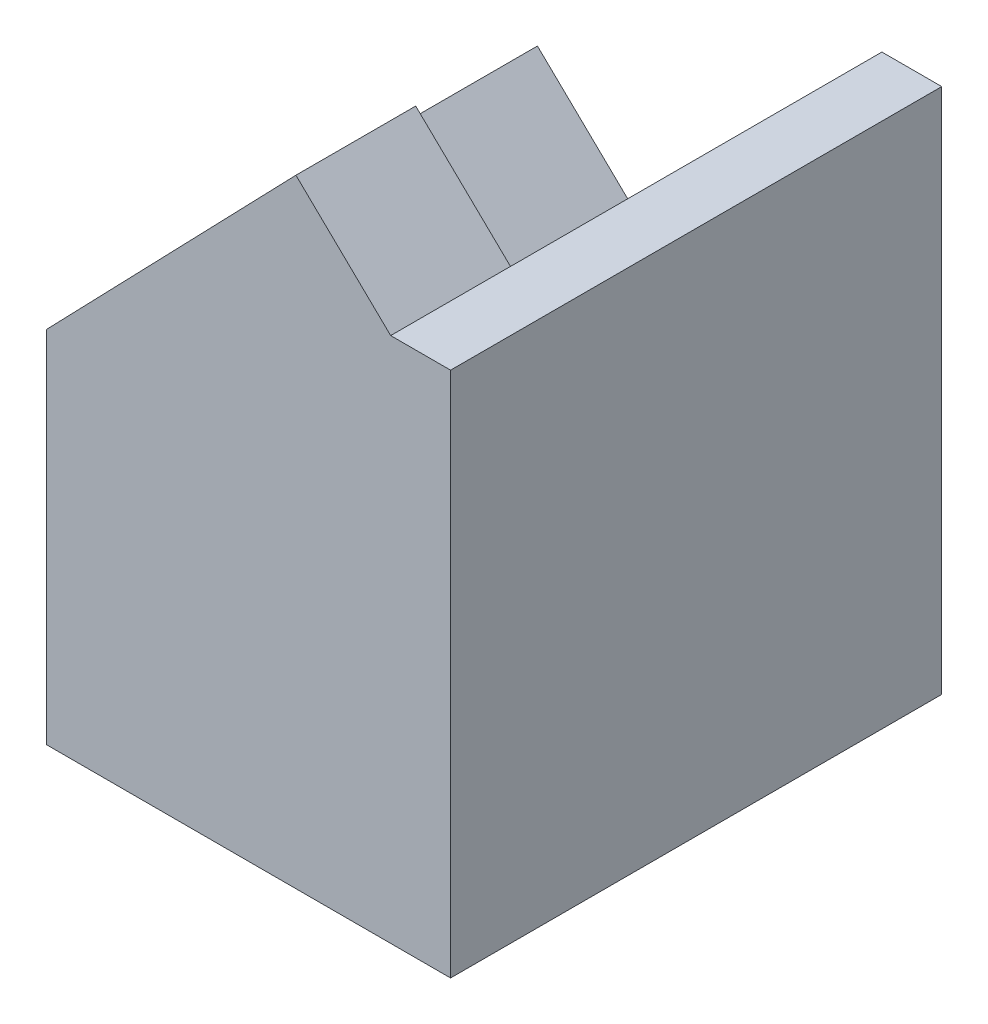
from build123d import *

# Parameters (mm, degrees)
BOSS_EXTRUDE1_DEPTH       = 8.2
CUT_EXTRUDE1_DEPTH        = 2.2
SKETCH3_W                 = 6.75
SKETCH3_H                 = 8.2
BOSS_EXTRUDE2_DEPTH       = 4
M2X0_4_TAPPED_HOLE1_D     = 1.6
M2X0_4_TAPPED_HOLE1_DEPTH = 4.7
M2X0_4_TAPPED_HOLE1_TIP   = 0.480688495
F_1_5MM_DOWEL_HOLE1_D     = 1.5
F_1_5MM_DOWEL_HOLE1_DEPTH = 3
F_1_5MM_DOWEL_HOLE1_TIP   = 0.450645464


with BuildPart() as part:
    # Sketch1 → Boss-Extrude1 (new body)
    with BuildSketch(Plane.XY):
        Polygon((0, 0), (6.75, 0), (6.75, 4.788271091), (5.75, 4.788271091), (4.167950223, 6.316038802), (0, 2), align=None)
    extrude(amount=BOSS_EXTRUDE1_DEPTH)

    # Sketch2 → Cut-Extrude1 (cut)
    with BuildSketch(Plane(origin=(-0.999390827, 0.965100503, 0), x_dir=(0.69465837, 0.7193398, 0), z_dir=(-0.7193398, 0.69465837, 0))):
        with BuildLine():
            Line((8.438679601, 0), (8.438679601, -6.2))
            Line((8.438679601, -6.2), (3.438679601, -6.2))
            Line((3.438679601, -6.2), (3.438679601, -6.45))
            ThreePointArc((3.438679601, -6.45), (2.438679601, -7.45), (1.438679601, -6.45))
            Line((1.438679601, -6.45), (1.438679601, 0))
            Line((1.438679601, 0), (8.438679601, 0))
        make_face()
    extrude(amount=-CUT_EXTRUDE1_DEPTH, mode=Mode.SUBTRACT)

    # Sketch3 → Boss-Extrude2 (add)
    with BuildSketch(Plane.XZ):
        with Locations((3.375, 4.1)):
            Rectangle(SKETCH3_W, SKETCH3_H)
    extrude(amount=BOSS_EXTRUDE2_DEPTH)

    # M2x0.4 Tapped Hole1
    with Locations(Plane(origin=(0, -4, 0), x_dir=(-1, 0, 0), z_dir=(0, -1, 0))):
        with Locations((-3.75, -4.1)):
            Hole(M2X0_4_TAPPED_HOLE1_D / 2, depth=M2X0_4_TAPPED_HOLE1_DEPTH)
            with Locations((0, 0, -(M2X0_4_TAPPED_HOLE1_DEPTH + M2X0_4_TAPPED_HOLE1_TIP / 2))):  # 118° drill point
                Cone(0, M2X0_4_TAPPED_HOLE1_D / 2, M2X0_4_TAPPED_HOLE1_TIP, mode=Mode.SUBTRACT)

    # Ø1.5mm Dowel Hole1
    with Locations(Plane(origin=(0, -4, 0), x_dir=(-1, 0, 0), z_dir=(0, -1, 0))):
        with Locations((-3.75, -7.1), (-3.75, -1.1)):
            Hole(F_1_5MM_DOWEL_HOLE1_D / 2, depth=F_1_5MM_DOWEL_HOLE1_DEPTH)
            with Locations((0, 0, -(F_1_5MM_DOWEL_HOLE1_DEPTH + F_1_5MM_DOWEL_HOLE1_TIP / 2))):  # 118° drill point
                Cone(0, F_1_5MM_DOWEL_HOLE1_D / 2, F_1_5MM_DOWEL_HOLE1_TIP, mode=Mode.SUBTRACT)


solid = part.part
